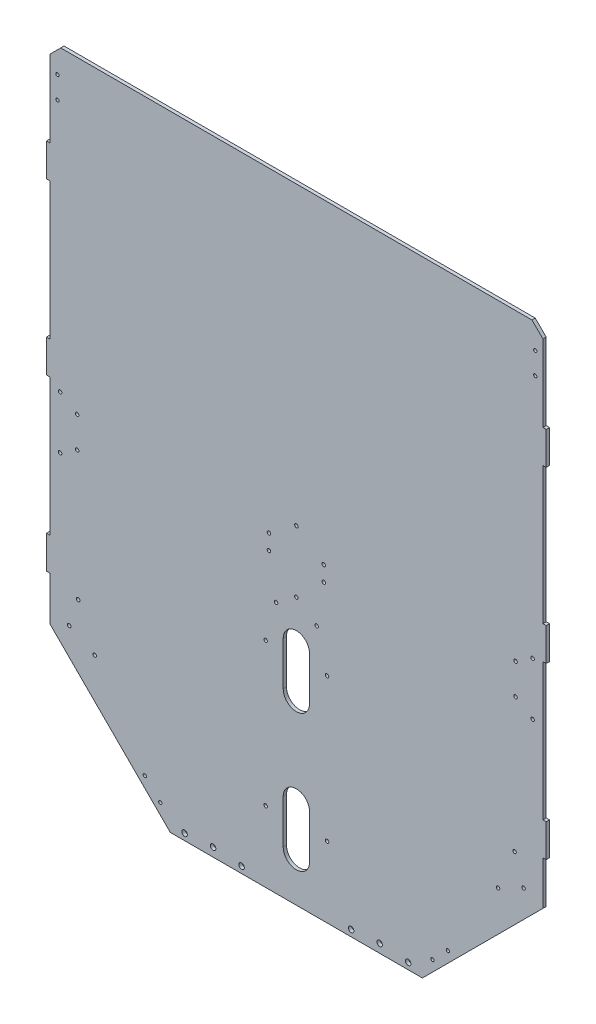
from build123d import *

# Parameters (mm, degrees)
EXTRUDE_1_DEPTH    = 3
CHAMFER1_SIZE      = 110
SKETCH1_R          = 2.5
CUT_EXTRUDE1_DEPTH = 10
SKETCH2_R          = 1.6
CUT_EXTRUDE2_DEPTH = 10
CUT_EXTRUDE3_DEPTH = 10
SKETCH4_R          = 1.6
CUT_EXTRUDE4_DEPTH = 8
SKETCH5_R          = 1.5
CUT_EXTRUDE5_DEPTH = 3
SKETCH6_R          = 1.6
CUT_EXTRUDE6_DEPTH = 3
CHAMFER2_SIZE      = 10
SKETCH7_R          = 1.6
CUT_EXTRUDE7_DEPTH = 10


with BuildPart() as part:
    # 草图1 → 凸台-拉伸1 (new body)
    with BuildSketch(Plane.XY):
        Polygon((-225, 205), (-228, 205), (-228, 175), (-225, 175), (-225, 50), (-228, 50), (-228, 20), (-225, 20), (-225, -105), (-228, -105), (-228, -135), (-225, -135), (-225, -285), (225, -285), (225, -135), (228, -135), (228, -105), (225, -105), (225, 20), (228, 20), (228, 50), (225, 50), (225, 175), (228, 175), (228, 205), (225, 205), (225, 285), (-225, 285), align=None)
    extrude(amount=EXTRUDE_1_DEPTH)

    # Chamfer1
    chamfer1_edges = [part.edges().sort_by_distance(p)[0] for p in [
        (225, -285, 1.5),
        (-225, -285, 1.5),
    ]]
    chamfer(chamfer1_edges, length=CHAMFER1_SIZE)

    # Sketch1 → Cut-Extrude1 (cut)
    with BuildSketch(Plane(origin=(0, 0, 0), x_dir=(-1, 0, 0), z_dir=(0, 0, -1))):
        with Locations((102, -279.1)):
            Circle(SKETCH1_R)
        with Locations((76, -277.1)):
            Circle(SKETCH1_R)
        with Locations((50, -279.1)):
            Circle(SKETCH1_R)
        with Locations((-50, -279.1)):
            Circle(SKETCH1_R)
        with Locations((-76, -277.1)):
            Circle(SKETCH1_R)
        with Locations((-102, -279.1)):
            Circle(SKETCH1_R)
    extrude(amount=-CUT_EXTRUDE1_DEPTH, mode=Mode.SUBTRACT)

    # Sketch2 → Cut-Extrude2 (cut)
    with BuildSketch(Plane.XY.offset(3)):
        with Locations((18.5, -55)):
            Circle(SKETCH2_R)
        with Locations((-18.5, -55)):
            Circle(SKETCH2_R)
        with Locations((0, -41.5)):
            Circle(SKETCH2_R)
    extrude(amount=-CUT_EXTRUDE2_DEPTH, mode=Mode.SUBTRACT)

    # Sketch3 → Cut-Extrude3 (cut)
    with BuildSketch(Plane.XY.offset(3)):
        with BuildLine():
            Line((-12, -245), (-12, -205))
            ThreePointArc((-12, -205), (0, -193), (12, -205))
            Line((12, -205), (12, -245))
            ThreePointArc((12, -245), (0, -257), (-12, -245))
        make_face()
        with BuildLine():
            Line((-12, -120), (-12, -80))
            ThreePointArc((-12, -80), (0, -68), (12, -80))
            Line((12, -80), (12, -120))
            ThreePointArc((12, -120), (0, -132), (-12, -120))
        make_face()
    extrude(amount=-CUT_EXTRUDE3_DEPTH, mode=Mode.SUBTRACT)

    # Sketch4 → Cut-Extrude4 (cut)
    with BuildSketch(Plane.XY.offset(3)):
        with Locations((184.062077547, -179.316911543)):
            Circle(SKETCH4_R)
        with Locations((207.289508253, -167.664074122)):
            Circle(SKETCH4_R)
        with Locations((199.105034852, -143)):
            Circle(SKETCH4_R)
        with Locations((215.571067812, -30.217453576)):
            Circle(SKETCH4_R)
        with Locations((200, -20.217453576)):
            Circle(SKETCH4_R)
        with Locations((200, 7.889501876)):
            Circle(SKETCH4_R)
        with Locations((215.571067812, 17.889501876)):
            Circle(SKETCH4_R)
        with Locations((-215.571067812, 12.870402688)):
            Circle(SKETCH4_R)
        with Locations((-200, 2.870402688)):
            Circle(SKETCH4_R)
        with Locations((-200, -25.236552763)):
            Circle(SKETCH4_R)
        with Locations((-215.571067812, -35.236552763)):
            Circle(SKETCH4_R)
        with Locations((-199.105034852, -143)):
            Circle(SKETCH4_R)
        with Locations((-207.289508253, -167.664074122)):
            Circle(SKETCH4_R)
        with Locations((-184.062077547, -179.316911543)):
            Circle(SKETCH4_R)
    extrude(amount=-CUT_EXTRUDE4_DEPTH, mode=Mode.SUBTRACT)

    # Sketch5 → Cut-Extrude5 (cut)
    with BuildSketch(Plane.XY.offset(3)):
        with Locations((124.192388155, -265.908116908)):
            Circle(SKETCH5_R)
        with Locations((138.334523779, -251.765981284)):
            Circle(SKETCH5_R)
        with Locations((218, 242.361547493)):
            Circle(SKETCH5_R)
        with Locations((218, 262.361547493)):
            Circle(SKETCH5_R)
        with Locations((-218, 262.361547493)):
            Circle(SKETCH5_R)
        with Locations((-218, 242.361547493)):
            Circle(SKETCH5_R)
        with Locations((-138.334523779, -251.765981284)):
            Circle(SKETCH5_R)
        with Locations((-124.192388155, -265.908116908)):
            Circle(SKETCH5_R)
    extrude(amount=-CUT_EXTRUDE5_DEPTH, mode=Mode.SUBTRACT)

    # Sketch6 → Cut-Extrude6 (cut)
    with BuildSketch(Plane(origin=(0, 0, 0), x_dir=(-1, 0, 0), z_dir=(0, 0, -1))):
        with Locations((-28, -89.618802154)):
            Circle(SKETCH6_R)
        with Locations((28, -89.618802154)):
            Circle(SKETCH6_R)
        with Locations((28, -220.381197846)):
            Circle(SKETCH6_R)
        with Locations((-28, -220.381197846)):
            Circle(SKETCH6_R)
    extrude(amount=-CUT_EXTRUDE6_DEPTH, mode=Mode.SUBTRACT)

    # Chamfer2
    chamfer2_edges = [part.edges().sort_by_distance(p)[0] for p in [
        (-225, 285, 1.5),
        (225, 285, 1.5),
    ]]
    chamfer(chamfer2_edges, length=CHAMFER2_SIZE)

    # Sketch7 → Cut-Extrude7 (cut)
    with BuildSketch(Plane.XY.offset(3)):
        with Locations((25, -17.236552763)):
            Circle(SKETCH7_R)
        with Locations((25, -3.342800748)):
            Circle(SKETCH7_R)
        with Locations((0, 14.870402688)):
            Circle(SKETCH7_R)
        with Locations((-25, -17.236552763)):
            Circle(SKETCH7_R)
        with Locations((-25, -3.342800748)):
            Circle(SKETCH7_R)
    extrude(amount=-CUT_EXTRUDE7_DEPTH, mode=Mode.SUBTRACT)


solid = part.part
